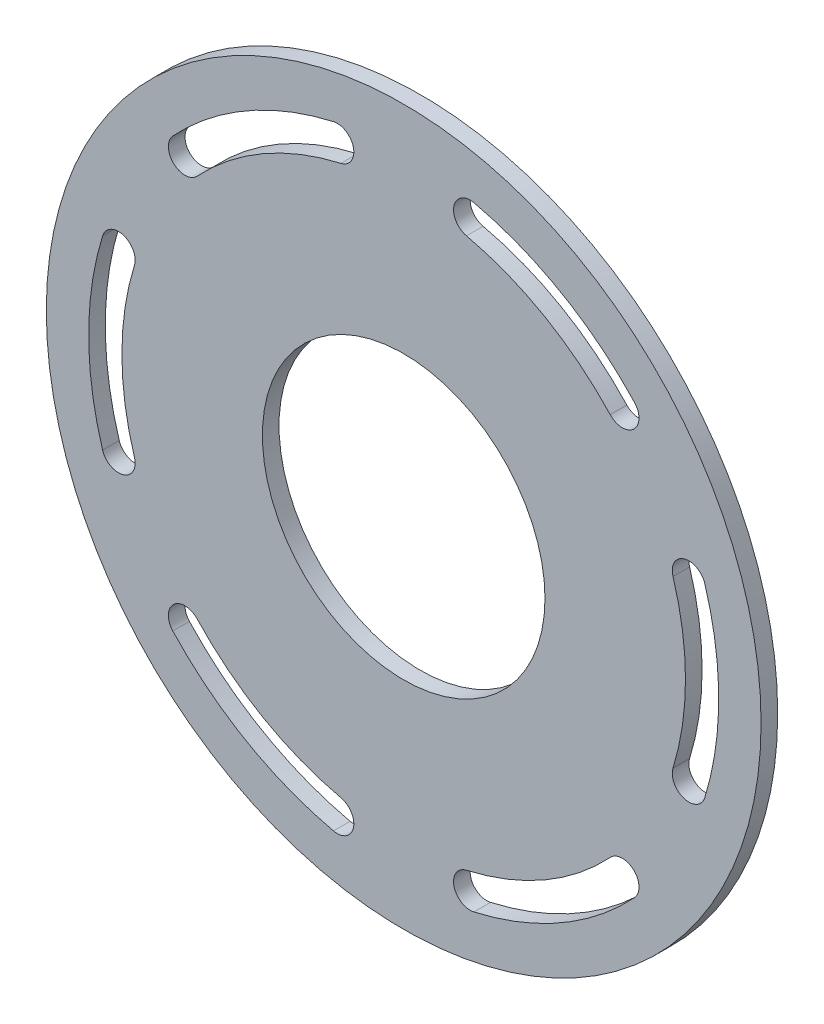
from build123d import *

# Parameters (mm, degrees)
SKETCH1_R           = 68.2625
SKETCH1_R_2         = 26.9875
BOSS_EXTRUDE1_DEPTH = 3.175


with BuildPart() as part:
    # Sketch1 → Boss-Extrude1 (new body)
    with BuildSketch(Plane.XY):
        Circle(SKETCH1_R)
        Circle(SKETCH1_R_2, mode=Mode.SUBTRACT)
        with BuildLine():
            ThreePointArc((-13.407442068, 58.659886532), (-30.0863, 52.111000212), (-44.097230886, 40.941128696))
            ThreePointArc((-44.097230886, 40.941128696), (-43.930699534, 36.454089884), (-39.443660721, 36.620621236))
            ThreePointArc((-39.443660721, 36.620621236), (-26.9113, 46.611738898), (-11.992557932, 52.46952282))
            ThreePointArc((-11.992557932, 52.46952282), (-9.604818144, 56.272146744), (-13.407442068, 58.659886532))
        make_face(mode=Mode.SUBTRACT)
        with BuildLine():
            ThreePointArc((39.443660721, 36.620621236), (26.9113, 46.611738898), (11.992557932, 52.46952282))
            ThreePointArc((11.992557932, 52.46952282), (9.604818144, 56.272146744), (13.407442068, 58.659886532))
            ThreePointArc((13.407442068, 58.659886532), (30.0863, 52.111000212), (44.097230886, 40.941128696))
            ThreePointArc((44.097230886, 40.941128696), (43.930699534, 36.454089884), (39.443660721, 36.620621236))
        make_face(mode=Mode.SUBTRACT)
        with BuildLine():
            ThreePointArc((51.436218653, -15.848901585), (53.8226, 0), (51.436218653, 15.848901585))
            ThreePointArc((51.436218653, 15.848901585), (53.535517678, 19.81805686), (57.504672954, 17.718757836))
            ThreePointArc((57.504672954, 17.718757836), (60.1726, 0), (57.504672954, -17.718757836))
            ThreePointArc((57.504672954, -17.718757836), (53.535517678, -19.81805686), (51.436218653, -15.848901585))
        make_face(mode=Mode.SUBTRACT)
        with BuildLine():
            ThreePointArc((11.992557932, -52.46952282), (26.9113, -46.611738898), (39.443660721, -36.620621236))
            ThreePointArc((39.443660721, -36.620621236), (43.930699534, -36.454089884), (44.097230886, -40.941128696))
            ThreePointArc((44.097230886, -40.941128696), (30.0863, -52.111000212), (13.407442068, -58.659886532))
            ThreePointArc((13.407442068, -58.659886532), (9.604818144, -56.272146744), (11.992557932, -52.46952282))
        make_face(mode=Mode.SUBTRACT)
        with BuildLine():
            ThreePointArc((-39.443660721, -36.620621236), (-26.9113, -46.611738898), (-11.992557932, -52.46952282))
            ThreePointArc((-11.992557932, -52.46952282), (-9.604818144, -56.272146744), (-13.407442068, -58.659886532))
            ThreePointArc((-13.407442068, -58.659886532), (-30.0863, -52.111000212), (-44.097230886, -40.941128696))
            ThreePointArc((-44.097230886, -40.941128696), (-43.930699534, -36.454089884), (-39.443660721, -36.620621236))
        make_face(mode=Mode.SUBTRACT)
        with BuildLine():
            ThreePointArc((-51.436218653, 15.848901585), (-53.8226, 0), (-51.436218653, -15.848901585))
            ThreePointArc((-51.436218653, -15.848901585), (-53.535517678, -19.81805686), (-57.504672954, -17.718757836))
            ThreePointArc((-57.504672954, -17.718757836), (-60.1726, 0), (-57.504672954, 17.718757836))
            ThreePointArc((-57.504672954, 17.718757836), (-53.535517678, 19.81805686), (-51.436218653, 15.848901585))
        make_face(mode=Mode.SUBTRACT)
    extrude(amount=BOSS_EXTRUDE1_DEPTH)


solid = part.part
